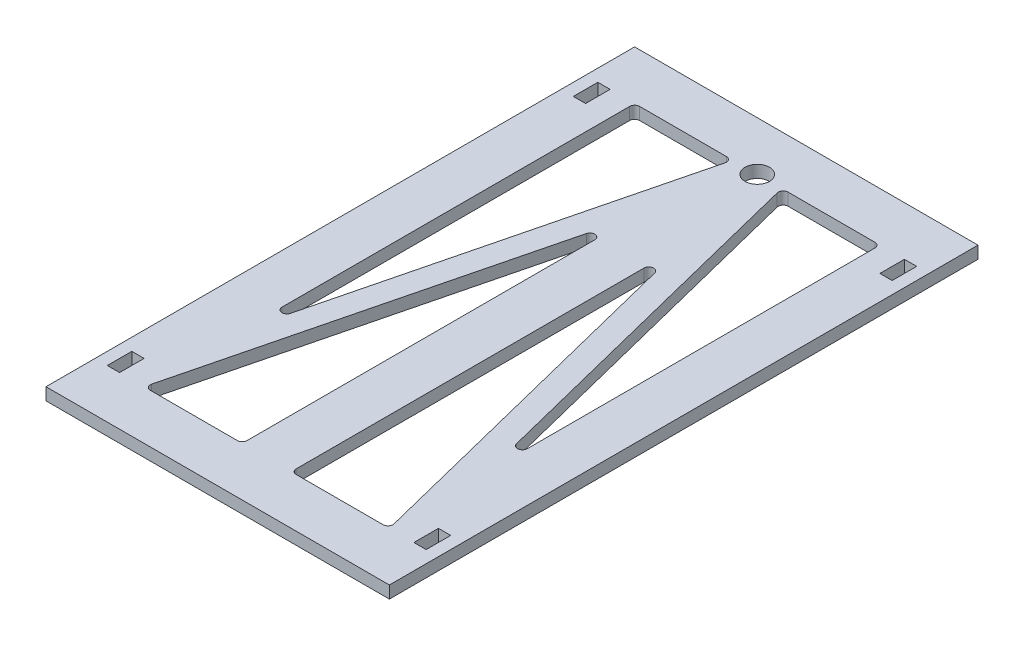
from build123d import *

# Parameters (mm, degrees)
SKETCH1_W         = 177.8
SKETCH1_H         = 304.8
SKETCH1_R         = 6.35
SKETCH1_W_2       = 6.35
SKETCH1_H_2       = 12.7
FRONT_PANEL_DEPTH = 6.35
FILLET1_R         = 2.54


with BuildPart() as part:
    # Sketch1 → Front Panel (new body)
    with BuildSketch(Plane(origin=(0, 0, 0), x_dir=(1, 0, 0), z_dir=(0, 1, 0))):
        with Locations((88.9, 152.4)):
            Rectangle(SKETCH1_W, SKETCH1_H)
        with Locations((88.9, 279.4)):
            Circle(SKETCH1_R, mode=Mode.SUBTRACT)
        with Locations((168.275, 273.05)):
            Rectangle(SKETCH1_W_2, SKETCH1_H_2, mode=Mode.SUBTRACT)
        with Locations((9.525, 273.05)):
            Rectangle(SKETCH1_W_2, SKETCH1_H_2, mode=Mode.SUBTRACT)
        with Locations((9.525, 31.75)):
            Rectangle(SKETCH1_W_2, SKETCH1_H_2, mode=Mode.SUBTRACT)
        with Locations((168.275, 31.75)):
            Rectangle(SKETCH1_W_2, SKETCH1_H_2, mode=Mode.SUBTRACT)
        Polygon((101.6, 279.4), (152.4, 279.4), (152.4, 76.2), align=None, mode=Mode.SUBTRACT)
        Polygon((101.6, 228.6), (101.6, 25.4), (152.4, 25.4), align=None, mode=Mode.SUBTRACT)
        Polygon((76.2, 279.4), (25.4, 279.4), (25.4, 76.2), align=None, mode=Mode.SUBTRACT)
        Polygon((76.2, 228.6), (76.2, 25.4), (25.4, 25.4), align=None, mode=Mode.SUBTRACT)
    extrude(amount=FRONT_PANEL_DEPTH)

    # Fillet1
    fillet1_edges = [part.edges().sort_by_distance(p)[0] for p in [
        (76.2, 3.175, -25.4),
        (76.2, 3.175, -228.6),
        (25.4, 3.175, -25.4),
        (76.2, 3.175, -279.4),
        (25.4, 3.175, -279.4),
        (25.4, 3.175, -76.2),
        (101.6, 3.175, -228.6),
        (101.6, 3.175, -25.4),
        (152.4, 3.175, -25.4),
        (152.4, 3.175, -279.4),
        (101.6, 3.175, -279.4),
        (152.4, 3.175, -76.2),
    ]]
    fillet(fillet1_edges, radius=FILLET1_R)


solid = part.part
